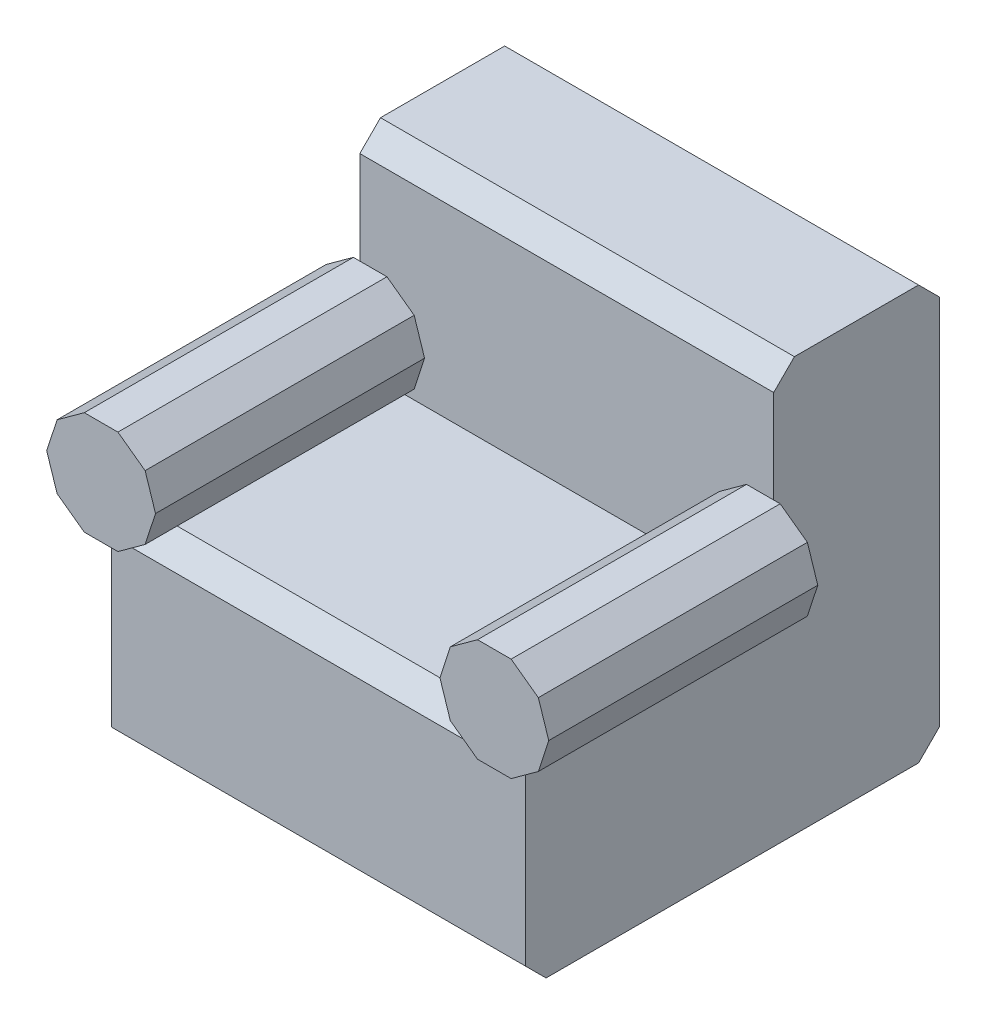
from build123d import *

# Parameters (mm, degrees)
BOSS_EXTRUDE1_DEPTH = 50
BOSS_EXTRUDE3_DEPTH = 65


with BuildPart() as part:
    # Sketch1 → Boss-Extrude1 (new body, symmetric)
    with BuildSketch(Plane(origin=(0, 0, 0), x_dir=(0, 0, -1), z_dir=(1, 0, 0))):
        Polygon((0, 0), (-55, 0), (-60, -5), (-60, -45), (-55, -50), (35, -50), (40, -45), (40, 45), (35, 50), (5, 50), (0, 45), align=None)
    extrude(amount=BOSS_EXTRUDE1_DEPTH, both=True)

    # Sketch2 → Boss-Extrude3 (add)
    with BuildSketch(Plane.XY):
        Polygon((60.643277803, 10), (58.133135104, 17.725424859), (51.561496203, 22.5), (43.438503797, 22.5), (36.866864896, 17.725424859), (34.356722197, 10), (36.866864896, 2.274575141), (43.438503797, -2.5), (51.561496203, -2.5), (58.133135104, 2.274575141), align=None)
    boss_extrude3 = extrude(amount=BOSS_EXTRUDE3_DEPTH)

    # Mirror1: Boss-Extrude3 across plane
    add(boss_extrude3.mirror(Plane(origin=(0, 0, 0), x_dir=(0, 0, 1), z_dir=(1, 0, 0))))


solid = part.part
